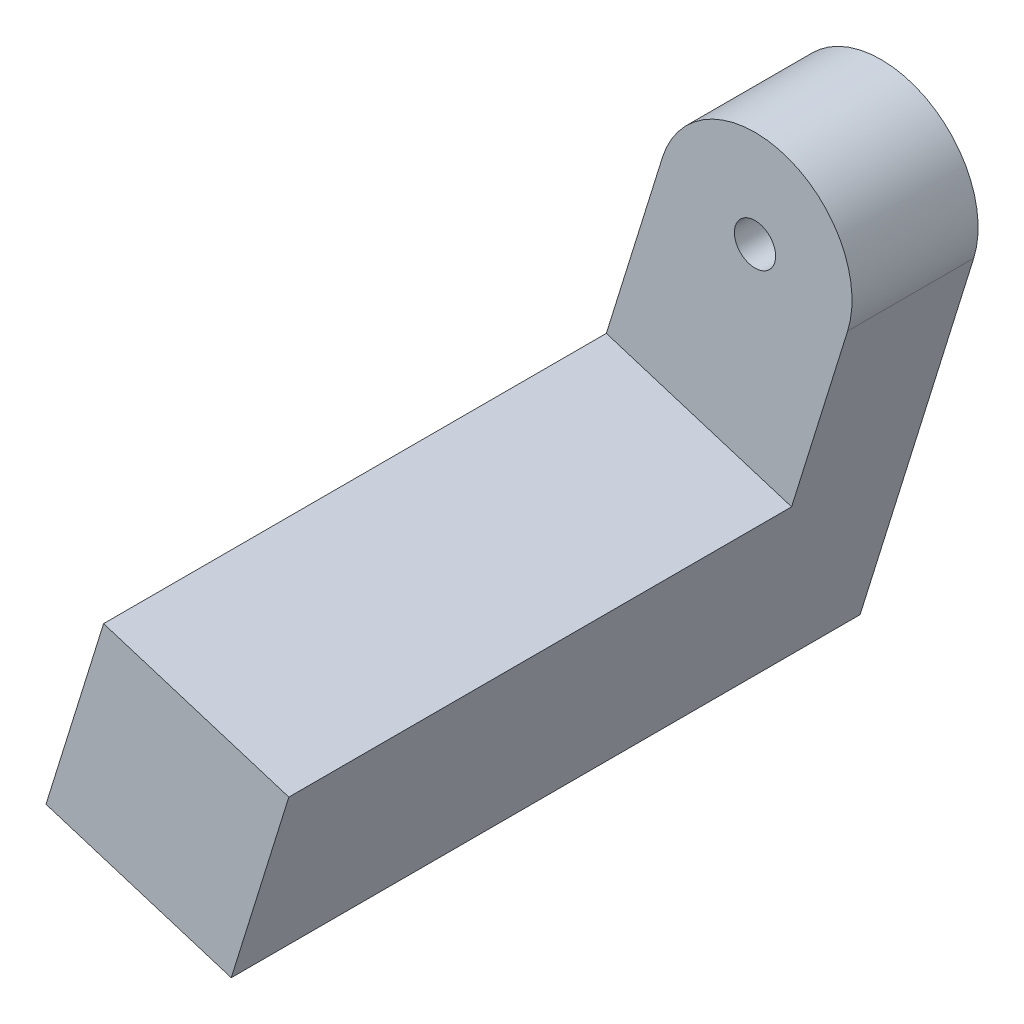
from build123d import *

# Parameters (mm, degrees)
SKETCH1_R           = 4
SKETCH1_R_2         = 2.3
BOSS_EXTRUDE1_DEPTH = 3.2
SKETCH2_R           = 4
SKETCH2_R_2         = 0.85
BOSS_EXTRUDE2_DEPTH = 2
BOSS_EXTRUDE3_DEPTH = 8
SKETCH6_R           = 0.85
CUT_EXTRUDE1_DEPTH  = 6.2


with BuildPart() as part:
    # Sketch1 → Boss-Extrude1 (new body)
    with BuildSketch(Plane.XY):
        Circle(SKETCH1_R)
        Circle(SKETCH1_R_2, mode=Mode.SUBTRACT)
    extrude(amount=-BOSS_EXTRUDE1_DEPTH)

    # Sketch2 → Boss-Extrude2 (add)
    with BuildSketch(Plane.XY):
        Circle(SKETCH2_R)
        Circle(SKETCH2_R_2, mode=Mode.SUBTRACT)
    extrude(amount=BOSS_EXTRUDE2_DEPTH)

    # Sketch5 → Boss-Extrude3 (add)
    with BuildSketch(Plane(origin=(3.819651946, -1.187543266, 0), x_dir=(0, 0, -1), z_dir=(0.954912987, -0.296885816, 0))):
        Polygon((-2, 0), (3.2, 0), (3.2, -15.784917441), (-22.731913212, -15.784917441), (-22.731913212, -7.784917441), (-2, -7.784917441), align=None)
    extrude(amount=-BOSS_EXTRUDE3_DEPTH)

    # Sketch6 → Cut-Extrude1 (cut, through all)
    with BuildSketch(Plane.XY.offset(2)):
        Circle(SKETCH6_R)
    extrude(amount=-CUT_EXTRUDE1_DEPTH, mode=Mode.SUBTRACT)


solid = part.part
